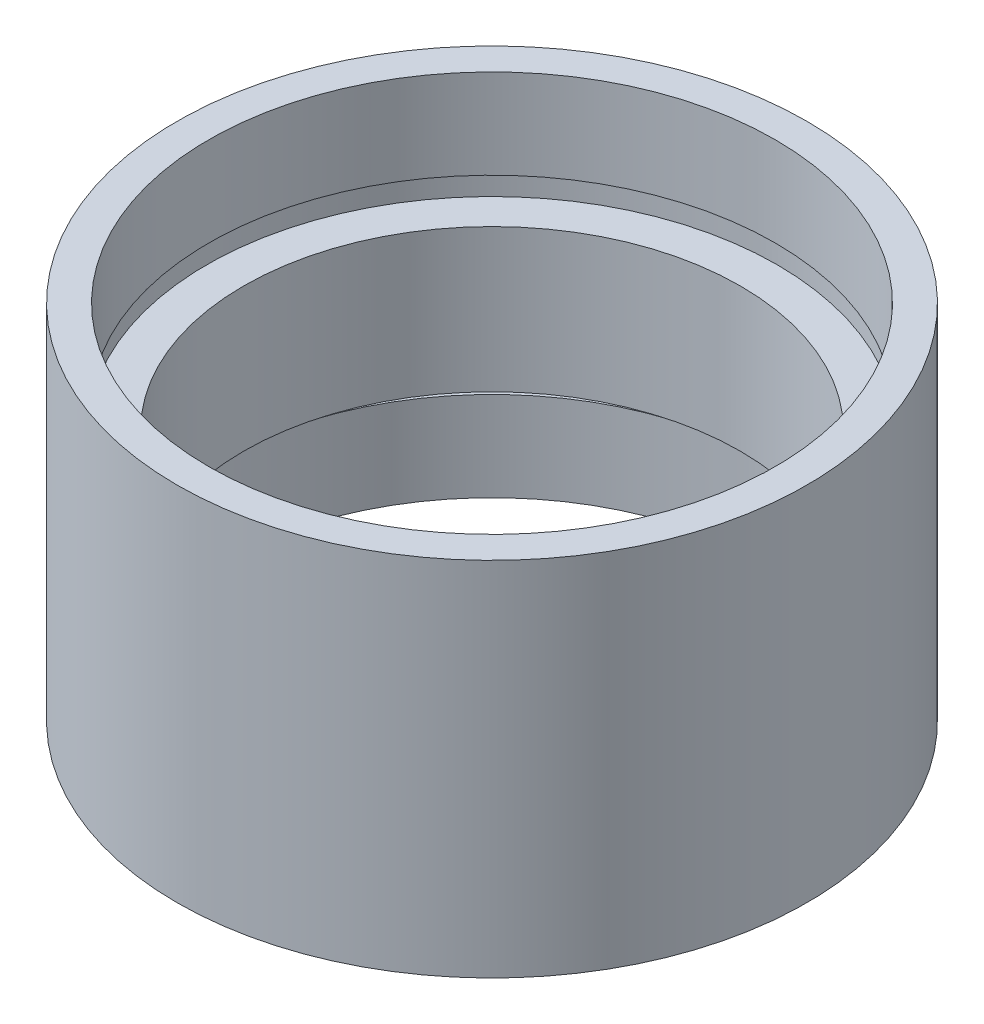
from build123d import *


with BuildPart() as part:
    # 草图1 → 旋转1 (revolve)
    with BuildSketch(Plane.XY, mode=Mode.PRIVATE) as revolve_1_sk:
        Polygon((13.75, 0), (13.75, 4.5), (14.35, 4.5), (14.35, 5.5), (12.5, 5.5), (12.5, 12.7), (14.35, 12.7), (14.35, 13.7), (14.25, 13.7), (14.25, 18.2), (15.85, 18.2), (15.85, 0), align=None)
    revolve(revolve_1_sk.sketch.rotate(Axis((0, 161.376166943, 0), (0, -1, 0)), 90), axis=Axis((0, 161.376166943, 0), (0, -1, 0)))  # turned: the seam where the file's is


solid = part.part
